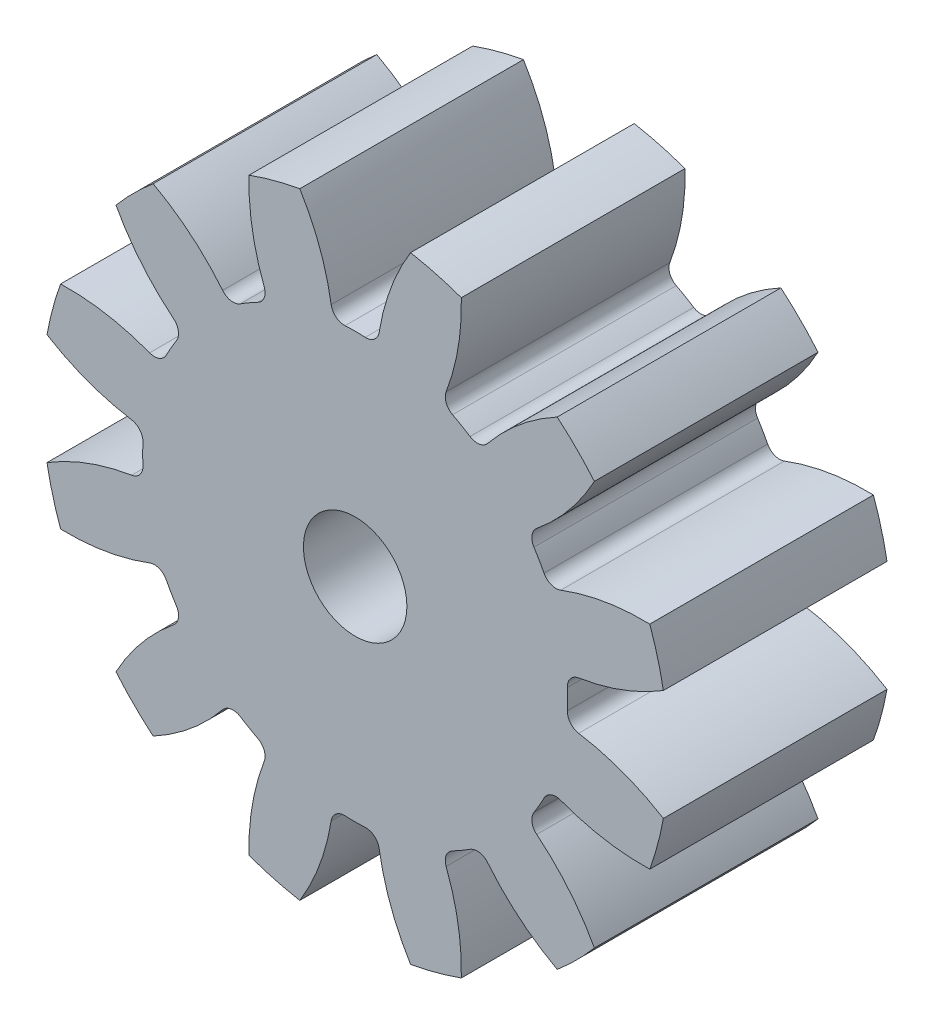
from build123d import *

# Parameters (mm, degrees)
SKETCH2_R                = 14
BOSS_EXTRUDE1_DEPTH      = 5
CUT_EXTRUDE1_DEPTH       = 6
FILLET1_R                = 0.6
CIRPATTERN1_COUNT        = 12
FILLET1_OF_CIRPATTERN1_R = 0.6
SKETCH4_R                = 2.3125
CUT_EXTRUDE2_DEPTH       = 3.5
SKETCH5_R                = 1.25
CUT_EXTRUDE3_DEPTH       = 11.0000001


with BuildPart() as part:
    # Sketch2 → Boss-Extrude1 (new body, symmetric)
    with BuildSketch(Plane.XY):
        Circle(SKETCH2_R)
    extrude(amount=BOSS_EXTRUDE1_DEPTH, both=True)

    # Sketch3 → Cut-Extrude1 (cut, symmetric)
    with BuildSketch(Plane.XY):
        with BuildLine():
            ThreePointArc((-0.999747632, 9.447248524), (-1.684900668, 12.207567555), (-3.095674935, 14.677084067))
            ThreePointArc((-3.095674935, 14.677084067), (0, 15), (3.095674935, 14.677084067))
            ThreePointArc((3.095674935, 14.677084067), (1.684900668, 12.207567555), (0.999747632, 9.447248524))
            ThreePointArc((0.999747632, 9.447248524), (0, 9.5), (-0.999747632, 9.447248524))
        make_face()
    cut_extrude1 = extrude(amount=CUT_EXTRUDE1_DEPTH, both=True, mode=Mode.SUBTRACT)

    # Fillet1
    fillet1_edges = [part.edges().sort_by_distance(p)[0] for p in [
        (-0.999747632, 9.447248524, 0),
        (0.999747632, 9.447248524, 0),
    ]]
    fillet(fillet1_edges, radius=FILLET1_R)

    # CirPattern1: Cut-Extrude1 ×12 about axis
    cirpattern1_axis = Axis((0, 0, 0), (0, 0, 1))
    for i in range(1, CIRPATTERN1_COUNT):
        add(cut_extrude1.rotate(cirpattern1_axis, i * 360 / CIRPATTERN1_COUNT), mode=Mode.SUBTRACT)

    # Fillet1 of CirPattern1
    fillet1_of_cirpattern1_edges = [part.edges().sort_by_distance(p)[0] for p in [
        (-5.589431109, 7.681683401, 0),
        (-3.857817415, 8.681431034, 0),
        (-8.681431034, 3.857817415, 0),
        (-7.681683401, 5.589431109, 0),
        (-9.447248524, -0.999747632, 0),
        (-9.447248524, 0.999747632, 0),
        (-7.681683401, -5.589431109, 0),
        (-8.681431034, -3.857817415, 0),
        (-3.857817415, -8.681431034, 0),
        (-5.589431109, -7.681683401, 0),
        (0.999747632, -9.447248524, 0),
        (-0.999747632, -9.447248524, 0),
        (5.589431109, -7.681683401, 0),
        (3.857817415, -8.681431034, 0),
        (8.681431034, -3.857817415, 0),
        (7.681683401, -5.589431109, 0),
        (9.447248524, 0.999747632, 0),
        (9.447248524, -0.999747632, 0),
        (7.681683401, 5.589431109, 0),
        (8.681431034, 3.857817415, 0),
        (3.857817415, 8.681431034, 0),
        (5.589431109, 7.681683401, 0),
    ]]
    fillet(fillet1_of_cirpattern1_edges, radius=FILLET1_OF_CIRPATTERN1_R)

    # Sketch4 → Cut-Extrude2 (cut)
    with BuildSketch(Plane.XY.offset(5)):
        Circle(SKETCH4_R)
    extrude(amount=-CUT_EXTRUDE2_DEPTH, mode=Mode.SUBTRACT)

    # Sketch5 → Cut-Extrude3 (cut, through all)
    with BuildSketch(Plane(origin=(0, 0, -5), x_dir=(-1, 0, 0), z_dir=(0, 0, -1))):
        Circle(SKETCH5_R)
    extrude(amount=-CUT_EXTRUDE3_DEPTH, mode=Mode.SUBTRACT)


solid = part.part
